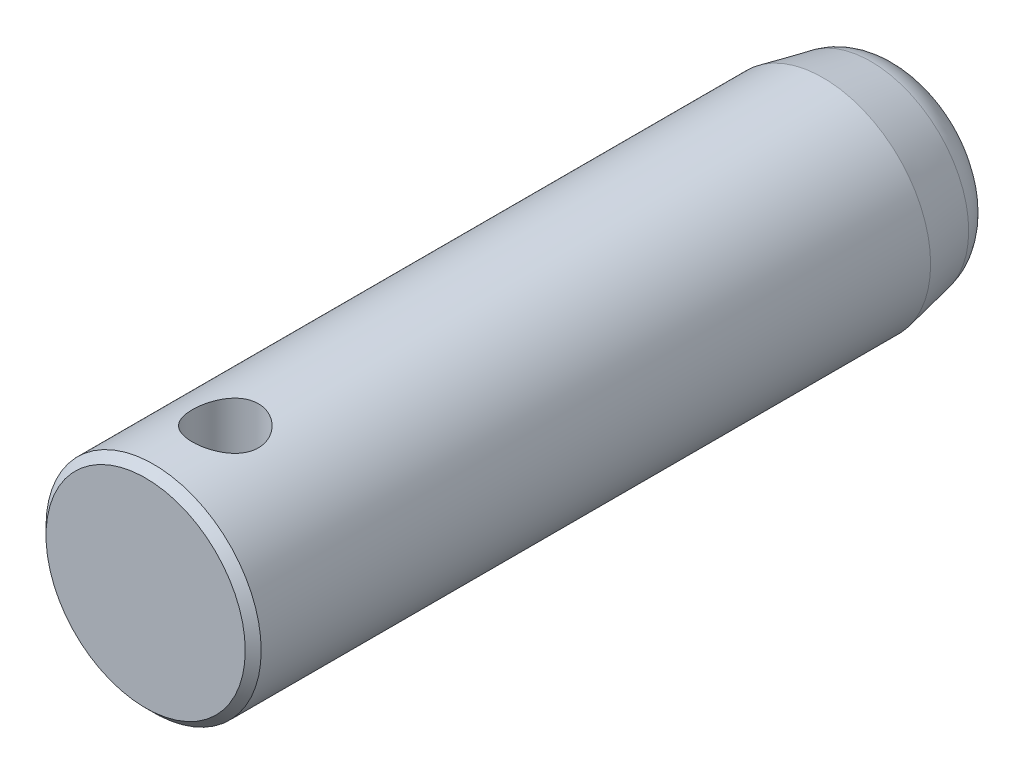
from build123d import *

# Parameters (mm, degrees)
CUT_EXTRUDE_1_REACH = 29
SKETCH_2_R          = 4.15


with BuildPart() as part:
    # 스케치1 → 회전1 (revolve)
    with BuildSketch(Plane(origin=(0, 0, 0), x_dir=(0, 0, -1), z_dir=(1, 0, 0)), mode=Mode.PRIVATE) as revolve_1_sk:
        with BuildLine():
            Line((1, 13.5), (85, 13.5))
            Line((85, 13.5), (90.996839672, 12.279929179))
            ThreePointArc((90.996839672, 12.279929179), (93.87196322, 10.543832299), (95, 7.380305656))
            Line((95, 7.380305656), (95, 0))
            Line((95, 0), (0, 0))
            Line((0, 0), (0, 12.5))
            Line((0, 12.5), (1, 13.5))
        make_face()
    revolve(revolve_1_sk.sketch.rotate(Axis((0, 0, 0), (0, 0, -1)), 90), axis=Axis((0, 0, 0), (0, 0, -1)))  # turned: the seam where the file's is

    # 스케치2 → 컷-돌출1 (cut, up to next)
    with BuildSketch(Plane(origin=(0, 13.5, 0), x_dir=(1, 0, 0), z_dir=(0, 1, 0)), mode=Mode.PRIVATE) as cut_extrude_1_sk1:
        with Locations(Location((0, 10, 0), (0, 0, 270))):  # turned: the seam where the file's is
            Circle(SKETCH_2_R)
    cut_extrude_1_tool1 = extrude(cut_extrude_1_sk1.sketch, amount=-CUT_EXTRUDE_1_REACH, mode=Mode.PRIVATE) & part.part
    add(cut_extrude_1_tool1.solids().sort_by_distance((0, 13.5, -10))[0], mode=Mode.SUBTRACT)


solid = part.part
